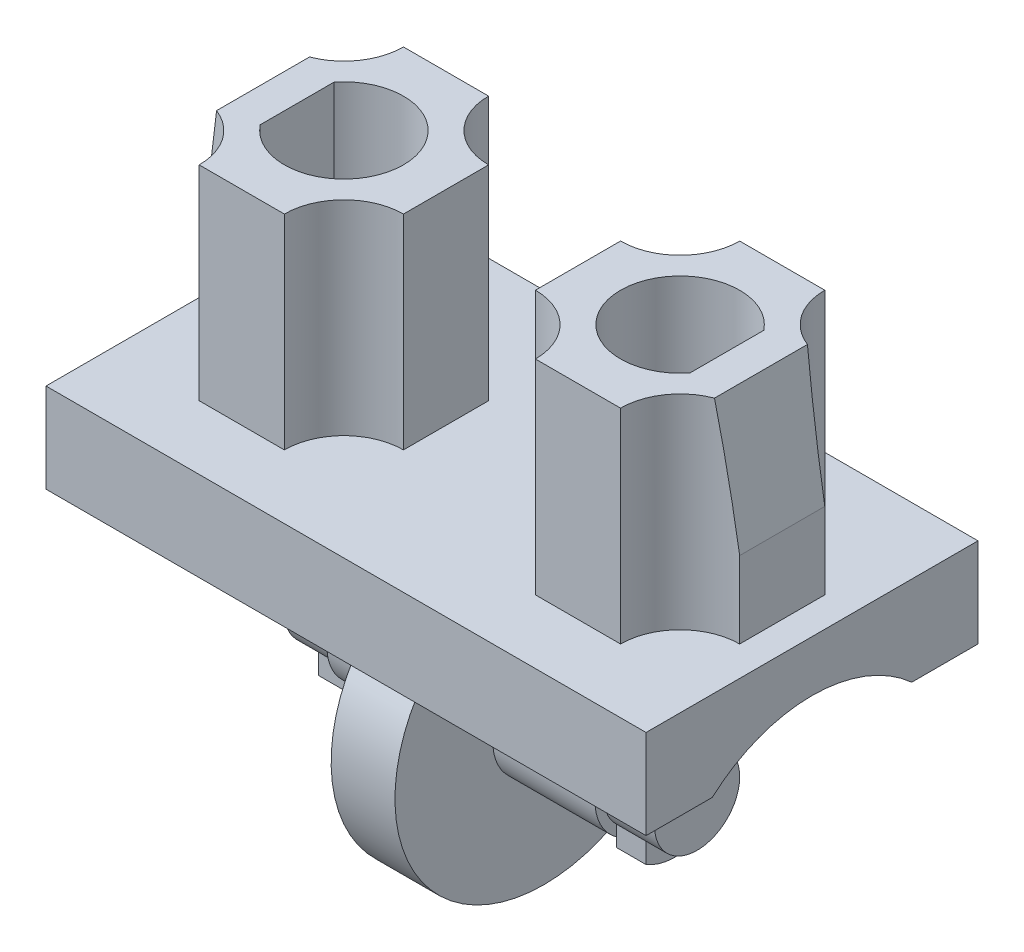
from build123d import *

# Parameters (mm, degrees)
HIB_BASE_DEPTH        = 7.05
SKETCH1_3_R           = 3.5
LEG_JOINT_DEPTH       = 0.75
SKETCH2_R             = 1.2
LEG_PEG_DEPTH         = 2.4
LEG_PEG_INNER_DEPTH   = 1.2
LEG_LOCK_DEPTH        = 0.7
HIP_PEG_DEPTH         = 4.8
HIP_CAVITY_DEPTH      = 4.8
HIP_PEG_CHAMFER_DEPTH = 4.9


with BuildPart() as part:
    # Sketch1 → Hib Base (new body, symmetric)
    with BuildSketch(Plane(origin=(0, 0, 0), x_dir=(0, 0, -1), z_dir=(1, 0, 0))):
        with BuildLine():
            ThreePointArc((-2.343074903, -2.1), (0, -1.2), (2.343074903, -2.1))
            Line((2.343074903, -2.1), (3.9, -2.1))
            Line((3.9, -2.1), (3.9, 0))
            Line((3.9, 0), (-3.9, 0))
            Line((-3.9, 0), (-3.9, -2.1))
            Line((-3.9, -2.1), (-2.343074903, -2.1))
        make_face()
    extrude(amount=HIB_BASE_DEPTH, both=True)

    # Sketch1_3 → Leg Joint (add, symmetric)
    with BuildSketch(Plane(origin=(0, 0, 0), x_dir=(0, 0, -1), z_dir=(1, 0, 0))):
        with Locations((0, -4.7)):
            Circle(SKETCH1_3_R)
    extrude(amount=LEG_JOINT_DEPTH, both=True)

    # Sketch2 → Leg Peg (add)
    with BuildSketch(Plane(origin=(0.75, 0, 0), x_dir=(0, 0, -1), z_dir=(1, 0, 0))):
        with Locations((0, -4.7)):
            Circle(SKETCH2_R)
    leg_peg = extrude(amount=LEG_PEG_DEPTH)

    # Sketch3 → Leg Peg Inner (add)
    with BuildSketch(Plane(origin=(3.15, 0, 0), x_dir=(0, 0, -1), z_dir=(1, 0, 0))):
        with BuildLine():
            Line((-0.661437828, -3.95), (0.661437828, -3.95))
            ThreePointArc((0.661437828, -3.95), (0, -5.7), (-0.661437828, -3.95))
        make_face()
    leg_peg_inner = extrude(amount=LEG_PEG_INNER_DEPTH)

    # Sketch4 → Leg Lock (add)
    with BuildSketch(Plane(origin=(3.15, 0, 0), x_dir=(0, 0, -1), z_dir=(1, 0, 0))):
        with BuildLine():
            Line((-0.7, -5.8892855), (-0.7, -5.414142843))
            ThreePointArc((-0.7, -5.414142843), (0, -5.7), (0.7, -5.414142843))
            Line((0.7, -5.414142843), (0.7, -5.8892855))
            ThreePointArc((0.7, -5.8892855), (0, -6.08), (-0.7, -5.8892855))
        make_face()
    leg_lock = extrude(amount=LEG_LOCK_DEPTH)

    # Sketch5 → Hip Peg (add)
    with BuildSketch(Plane(origin=(0, 0, 0), x_dir=(1, 0, 0), z_dir=(0, 1, 0))):
        with BuildLine():
            ThreePointArc((1.55, -1), (2.539949494, -1.410050506), (2.95, -2.4))
            Line((2.95, -2.4), (4.95, -2.4))
            ThreePointArc((4.95, -2.4), (5.360050506, -1.410050506), (6.35, -1))
            Line((6.35, -1), (6.35, 1))
            ThreePointArc((6.35, 1), (5.360050506, 1.410050506), (4.95, 2.4))
            Line((4.95, 2.4), (2.95, 2.4))
            ThreePointArc((2.95, 2.4), (2.539949494, 1.410050506), (1.55, 1))
            Line((1.55, 1), (1.55, -1))
        make_face()
    hip_peg = extrude(amount=HIP_PEG_DEPTH)

    # Sketch6 → Hip Cavity (cut)
    with BuildSketch(Plane(origin=(0, 4.8, 0), x_dir=(1, 0, 0), z_dir=(0, 1, 0))):
        with BuildLine():
            Line((5.05, 0.866025404), (5.05, -0.866025404))
            ThreePointArc((5.05, -0.866025404), (2.55, 0), (5.05, 0.866025404))
        make_face()
    hip_cavity = extrude(amount=-HIP_CAVITY_DEPTH, mode=Mode.SUBTRACT)

    # Sketch7 → Hip Peg Chamfer (cut, symmetric)
    with BuildSketch(Plane.XY):
        Polygon((6.35, 4.8), (6.35, 1.8), (5.85, 4.8), align=None)
    hip_peg_chamfer = extrude(amount=HIP_PEG_CHAMFER_DEPTH, both=True, mode=Mode.SUBTRACT)

    # Mirror1: Leg Peg, Leg Peg Inner, Leg Lock, Hip Peg, Hip Cavity, Hip Peg Chamfer across plane
    add(leg_peg.mirror(Plane(origin=(0, 0, 0), x_dir=(0, 0, 1), z_dir=(1, 0, 0))))
    add(leg_peg_inner.mirror(Plane(origin=(0, 0, 0), x_dir=(0, 0, 1), z_dir=(1, 0, 0))))
    add(leg_lock.mirror(Plane(origin=(0, 0, 0), x_dir=(0, 0, 1), z_dir=(1, 0, 0))))
    add(hip_peg.mirror(Plane(origin=(0, 0, 0), x_dir=(0, 0, 1), z_dir=(1, 0, 0))))
    add(hip_cavity.mirror(Plane(origin=(0, 0, 0), x_dir=(0, 0, 1), z_dir=(1, 0, 0))), mode=Mode.SUBTRACT)
    add(hip_peg_chamfer.mirror(Plane(origin=(0, 0, 0), x_dir=(0, 0, 1), z_dir=(1, 0, 0))), mode=Mode.SUBTRACT)


solid = part.part
